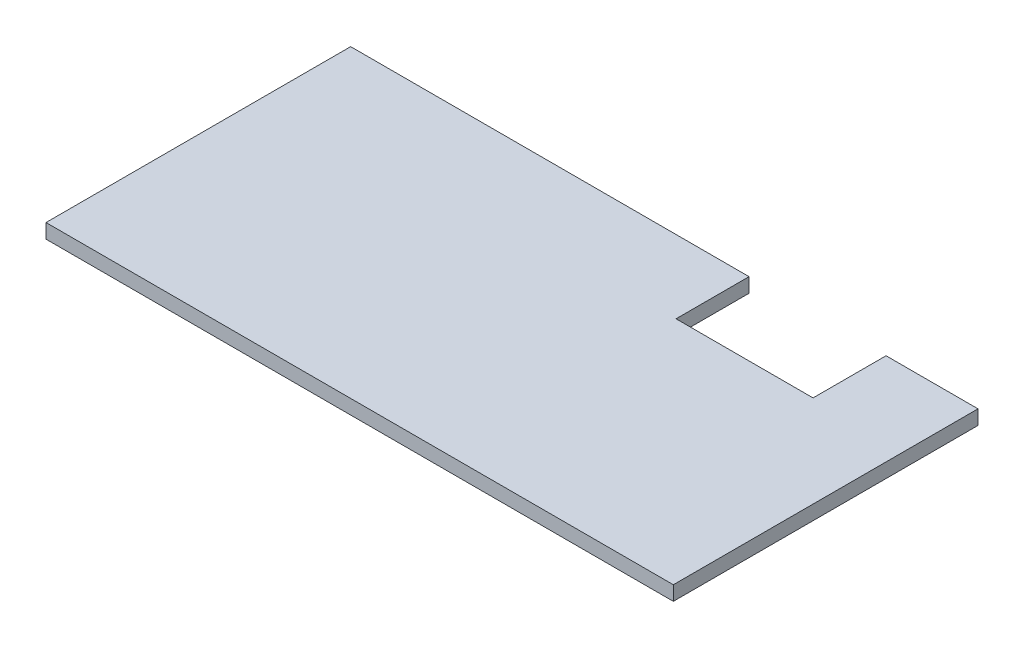
from build123d import *

# Parameters (mm, degrees)
SKETCH1_W           = 69.6
SKETCH1_H           = 33.8
BOSS_EXTRUDE2_DEPTH = 1.6
SKETCH5_W           = 15.2
SKETCH5_H           = 8.1
CUT_EXTRUDE6_DEPTH  = 10


with BuildPart() as part:
    # Sketch1 → Boss-Extrude2 (new body)
    with BuildSketch(Plane(origin=(0, 0, 0), x_dir=(1, 0, 0), z_dir=(0, 1, 0))):
        with Locations((5, 7.62)):
            Rectangle(SKETCH1_W, SKETCH1_H)
    extrude(amount=BOSS_EXTRUDE2_DEPTH)

    # Sketch5 → Cut-Extrude6 (cut)
    with BuildSketch(Plane(origin=(0, 1.6, 0), x_dir=(1, 0, 0), z_dir=(0, 1, 0))):
        with Locations((22, 20.47)):
            Rectangle(SKETCH5_W, SKETCH5_H)
    extrude(amount=-CUT_EXTRUDE6_DEPTH, mode=Mode.SUBTRACT)


solid = part.part
